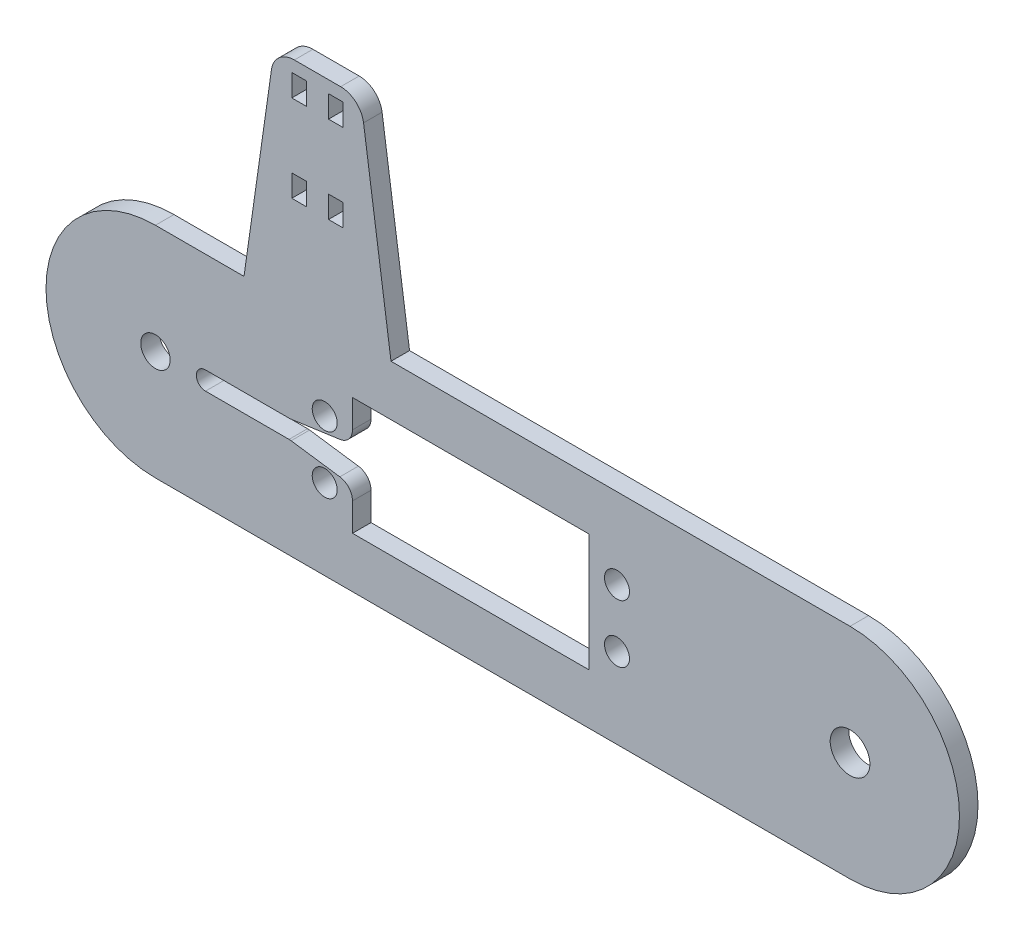
from build123d import *

# Parameters (mm, degrees)
SKETCH1_R           = 3.429
SKETCH1_R_2         = 2.54
BOSS_EXTRUDE1_DEPTH = 3.2004
SKETCH5_R           = 2.159
SKETCH5_W           = 40.894
SKETCH5_H           = 20.32
CUT_EXTRUDE3_DEPTH  = 4.2004
CUT_EXTRUDE4_DEPTH  = 3.2004
CUT_EXTRUDE5_DEPTH  = 3.2004
SKETCH9_W           = 2.54
SKETCH9_H           = 3.81
BOSS_EXTRUDE2_DEPTH = 3.2004
FILLET1_R           = 2.54


with BuildPart() as part:
    # Sketch1 → Boss-Extrude1 (new body)
    with BuildSketch(Plane.XY):
        with BuildLine():
            Line((120.015, 37.81552), (0, 37.81552))
            ThreePointArc((0, 37.81552), (-18.90776, 18.90776), (0, 0))
            Line((0, 0), (120.015, 0))
            ThreePointArc((120.015, 0), (138.92276, 18.90776), (120.015, 37.81552))
        make_face()
        with Locations((120.015, 18.90776)):
            Circle(SKETCH1_R, mode=Mode.SUBTRACT)
        with Locations((0, 18.90776)):
            Circle(SKETCH1_R_2, mode=Mode.SUBTRACT)
    extrude(amount=BOSS_EXTRUDE1_DEPTH)

    # Sketch5 → Cut-Extrude3 (cut, through all)
    with BuildSketch(Plane(origin=(0, 0, 0), x_dir=(-1, 0, 0), z_dir=(0, 0, -1))):
        with Locations((-79.746999972, 23.90776)):
            Circle(SKETCH5_R)
        with Locations((-29.246999972, 13.90776)):
            Circle(SKETCH5_R)
        with Locations((-29.246999972, 23.90776)):
            Circle(SKETCH5_R)
        with Locations((-79.746999972, 13.90776)):
            Circle(SKETCH5_R)
        with Locations((-54.496999972, 18.90776)):
            Rectangle(SKETCH5_W, SKETCH5_H)
    extrude(amount=-CUT_EXTRUDE3_DEPTH, mode=Mode.SUBTRACT)

    # Sketch6 → Cut-Extrude4 (cut)
    with BuildSketch(Plane.XY.offset(3.2004)):
        with BuildLine():
            Line((8.649999972, 20.49526), (25.159999972, 20.49526))
            ThreePointArc((25.159999972, 20.49526), (26.747499972, 18.90776), (25.159999972, 17.32026))
            Line((25.159999972, 17.32026), (8.649999972, 17.32026))
            ThreePointArc((8.649999972, 17.32026), (7.062499972, 18.90776), (8.649999972, 20.49526))
        make_face()
    extrude(amount=-CUT_EXTRUDE4_DEPTH, mode=Mode.SUBTRACT)

    # Sketch8 → Cut-Extrude5 (cut)
    with BuildSketch(Plane.XY.offset(3.2004)):
        Polygon((34.049999972, 15.79626), (34.049999972, 22.01926), (23.264769203, 20.49526), (23.264769203, 17.32026), align=None)
    extrude(amount=-CUT_EXTRUDE5_DEPTH, mode=Mode.SUBTRACT)

    # Sketch9 → Boss-Extrude2 (add)
    with BuildSketch(Plane(origin=(0, 0, 0), x_dir=(-1, 0, 0), z_dir=(0, 0, -1))):
        with BuildLine():
            Line((-40.703500071, 37.81552), (-15.303500071, 37.81552))
            Line((-15.303500071, 37.81552), (-20.045783141, 71.118080223))
            ThreePointArc((-20.045783141, 71.118080223), (-21.383392309, 73.573639076), (-24.003000071, 74.551710005))
            Line((-24.003000071, 74.551710005), (-32.004000071, 74.551710005))
            ThreePointArc((-32.004000071, 74.551710005), (-34.623607833, 73.573639076), (-35.961217, 71.118080223))
            Line((-35.961217, 71.118080223), (-40.703500071, 37.81552))
        make_face()
        with Locations((-31.178500071, 55.533488225)):
            Rectangle(SKETCH9_W, SKETCH9_H, mode=Mode.SUBTRACT)
        with Locations((-24.828500071, 55.533488225)):
            Rectangle(SKETCH9_W, SKETCH9_H, mode=Mode.SUBTRACT)
        with Locations((-31.178500071, 70.554572711)):
            Rectangle(SKETCH9_W, SKETCH9_H, mode=Mode.SUBTRACT)
        with Locations((-24.828500071, 70.554572711)):
            Rectangle(SKETCH9_W, SKETCH9_H, mode=Mode.SUBTRACT)
    extrude(amount=-BOSS_EXTRUDE2_DEPTH)

    # Fillet1
    fillet1_edges = [part.edges().sort_by_distance(p)[0] for p in [
        (34.049999972, 22.01926, 1.6002),
        (23.264769203, 20.49526, 1.6002),
        (23.264769203, 17.32026, 1.6002),
        (34.049999972, 15.79626, 1.6002),
    ]]
    fillet(fillet1_edges, radius=FILLET1_R)


solid = part.part
